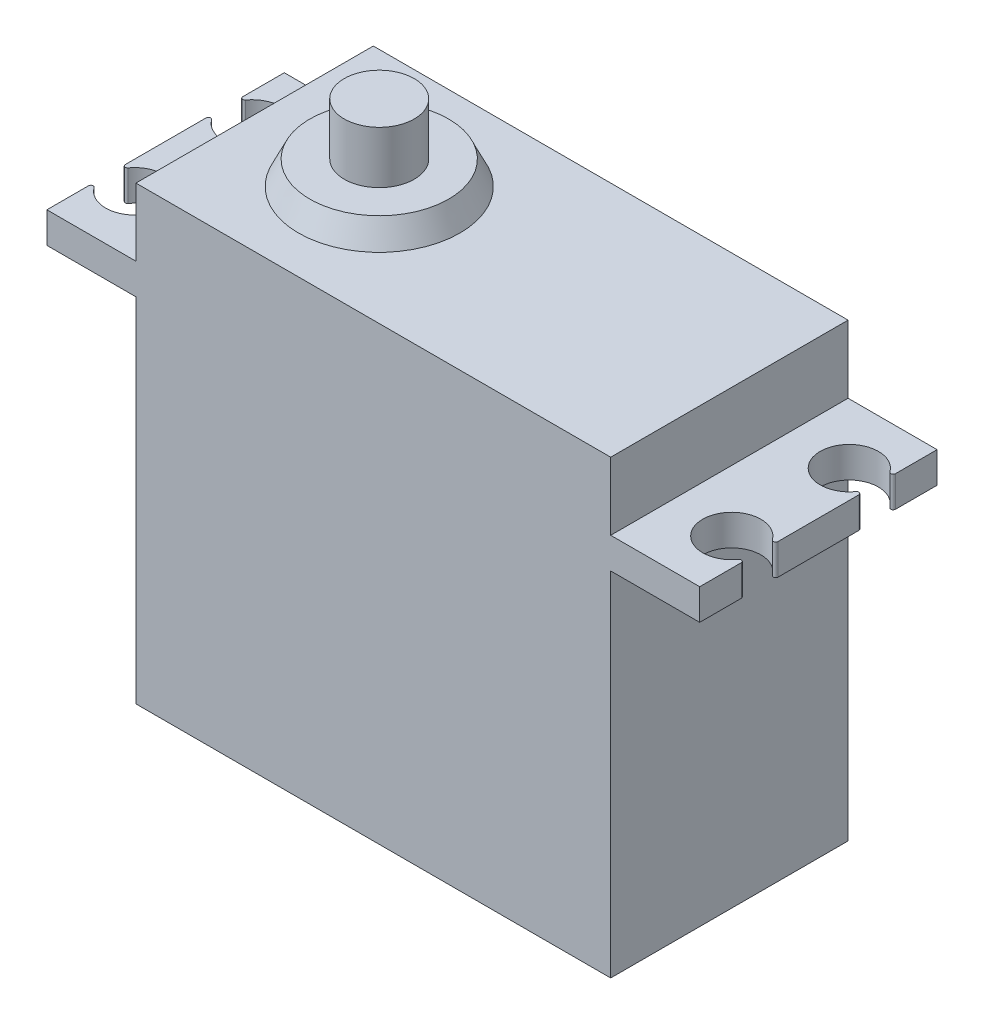
from build123d import *

# Parameters (mm, degrees)
RESSALTO_EXTRUS_O1_DEPTH = 10
ESBO_O3_R                = 2.45
CORTE_EXTRUS_O1_DEPTH    = 51.122749326
FILETE1_R                = 0.2


with BuildPart() as part:
    # Esboço1 → Ressalto-extrusão1 (new, symmetric)
    with BuildSketch(Plane.XY):
        Polygon((-10.5, 0), (-10.5, -5.7), (-18, -5.7), (-18, -8.3), (-10.5, -8.3), (-10.5, -38), (29.5, -38), (29.5, -8.3), (37, -8.3), (37, -5.7), (29.5, -5.7), (29.5, 0), align=None)
    extrude(amount=RESSALTO_EXTRUS_O1_DEPTH, both=True)

    # Esboço1<3> → Revolução1 (revolve)
    with BuildSketch(Plane.XY):
        Polygon((0, 0), (6.8, 0), (5.85, 2), (2.95, 2), (2.95, 6.4), (0, 6.4), align=None)
    revolve(axis=Axis((0, 0, 0), (0, 1, 0)))

    # Esboço3 → Corte-extrusão1 (cut, through all)
    with BuildSketch(Plane(origin=(0, -5.7, 0), x_dir=(1, 0, 0), z_dir=(0, 1, 0))):
        with Locations((-15.65, 4.95)):
            Circle(ESBO_O3_R)
        with Locations((-15.65, -4.95)):
            Circle(ESBO_O3_R)
        with Locations((34.65, -4.95)):
            Circle(ESBO_O3_R)
        with Locations((34.65, 4.95)):
            Circle(ESBO_O3_R)
    extrude(amount=-CORTE_EXTRUS_O1_DEPTH, mode=Mode.SUBTRACT)

    # Filete1
    filete1_edges = [part.edges().sort_by_distance(p)[0] for p in [
        (37, -7, 5.642820323),
        (37, -7, -4.257179677),
        (37, -7, 4.257179677),
        (37, -7, -5.642820323),
        (-18, -7, 4.257179677),
        (-18, -7, 5.642820323),
        (-18, -7, -4.257179677),
        (-18, -7, -5.642820323),
    ]]
    fillet(filete1_edges, radius=FILETE1_R)


solid = part.part
